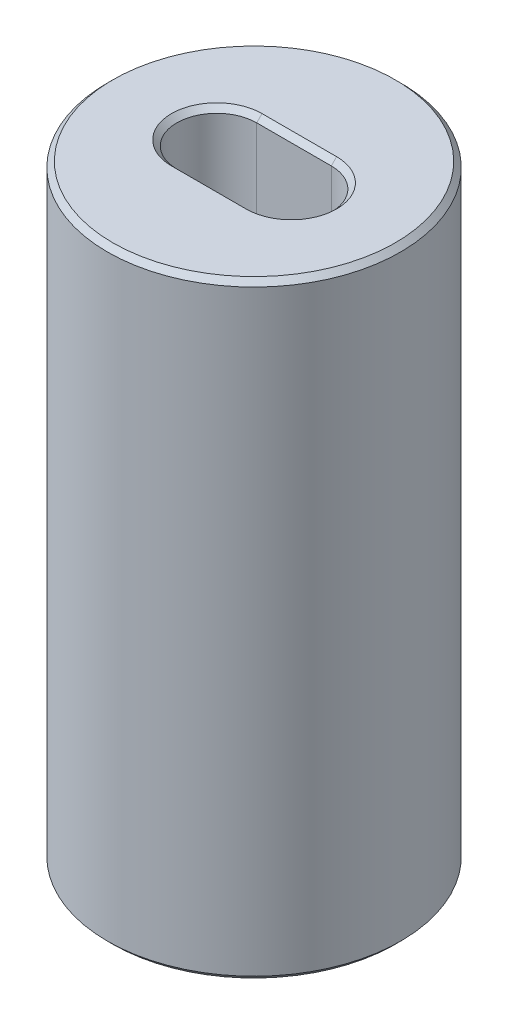
from build123d import *

# Parameters (mm, degrees)
SKETCH1_R          = 2.75
SKETCH1_R_2        = 1.45
MAIN_EXTRUDE_DEPTH = 5.7
MAIN_CHAMFER_SIZE  = 0.1


with BuildPart() as part:
    # Sketch1 → main extrude (new body, symmetric)
    with BuildSketch(Plane(origin=(0, 0, 0), x_dir=(1, 0, 0), z_dir=(0, 1, 0))):
        Circle(SKETCH1_R)
        Circle(SKETCH1_R_2, mode=Mode.SUBTRACT)
        with BuildLine():
            ThreePointArc((-0.7, -0.75), (-1.230330086, -0.530330086), (-1.45, 0))
            ThreePointArc((-1.45, 0), (0, -1.45), (1.45, 0))
            ThreePointArc((1.45, 0), (1.230330086, -0.530330086), (0.7, -0.75))
            Line((0.7, -0.75), (-0.7, -0.75))
        make_face()
        with BuildLine():
            ThreePointArc((-1.45, 0), (-1.230330086, 0.530330086), (-0.7, 0.75))
            Line((-0.7, 0.75), (0.7, 0.75))
            ThreePointArc((0.7, 0.75), (1.230330086, 0.530330086), (1.45, 0))
            ThreePointArc((1.45, 0), (0, 1.45), (-1.45, 0))
        make_face()
    extrude(amount=MAIN_EXTRUDE_DEPTH, both=True)

    # main chamfer
    main_chamfer_edges = [part.edges().sort_by_distance(p)[0] for p in [
        (0, 5.7, 0.75),
        (-1.45, 5.7, 0),
        (-2.75, 5.7, 0),
        (0, 5.7, -0.75),
        (-2.75, -5.7, 0),
        (-1.45, -5.7, 0),
        (0, -5.7, 0.75),
        (1.45, -5.7, 0),
        (0, -5.7, -0.75),
        (1.45, 5.7, 0),
    ]]
    chamfer(main_chamfer_edges, length=MAIN_CHAMFER_SIZE)


solid = part.part
